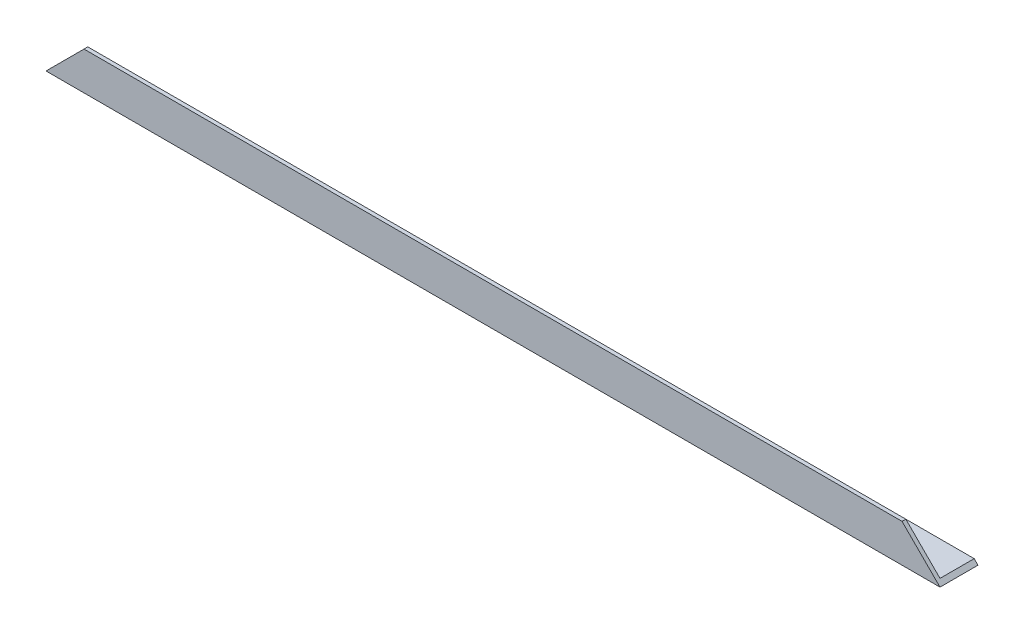
from build123d import *

# Parameters (mm, degrees)
EXTRUDE_1_DEPTH     = 353
CUT_EXTRUDE_1_DEPTH = 16


with BuildPart() as part:
    # Эскиз1 → Бобышка-Вытянуть1 (new body)
    with BuildSketch(Plane(origin=(0, 0, 0), x_dir=(0, 0, -1), z_dir=(1, 0, 0))):
        Polygon((0, 0), (0, 15), (1.5, 15), (1.5, 1.5), (15, 1.5), (15, 0), align=None)
    extrude(amount=EXTRUDE_1_DEPTH)

    # Эскиз2 → Вырез-Вытянуть1 (cut, through all)
    with BuildSketch(Plane.XY):
        Polygon((0, 0), (21.729873861, 21.729873861), (0, 21.729873861), align=None)
    cut_extrude_1 = extrude(amount=-CUT_EXTRUDE_1_DEPTH, mode=Mode.SUBTRACT)

    # Зеркальное отражение1: Вырез-Вытянуть1 across plane
    add(cut_extrude_1.mirror(Plane.ZY.offset(-176.5)), mode=Mode.SUBTRACT)


solid = part.part
